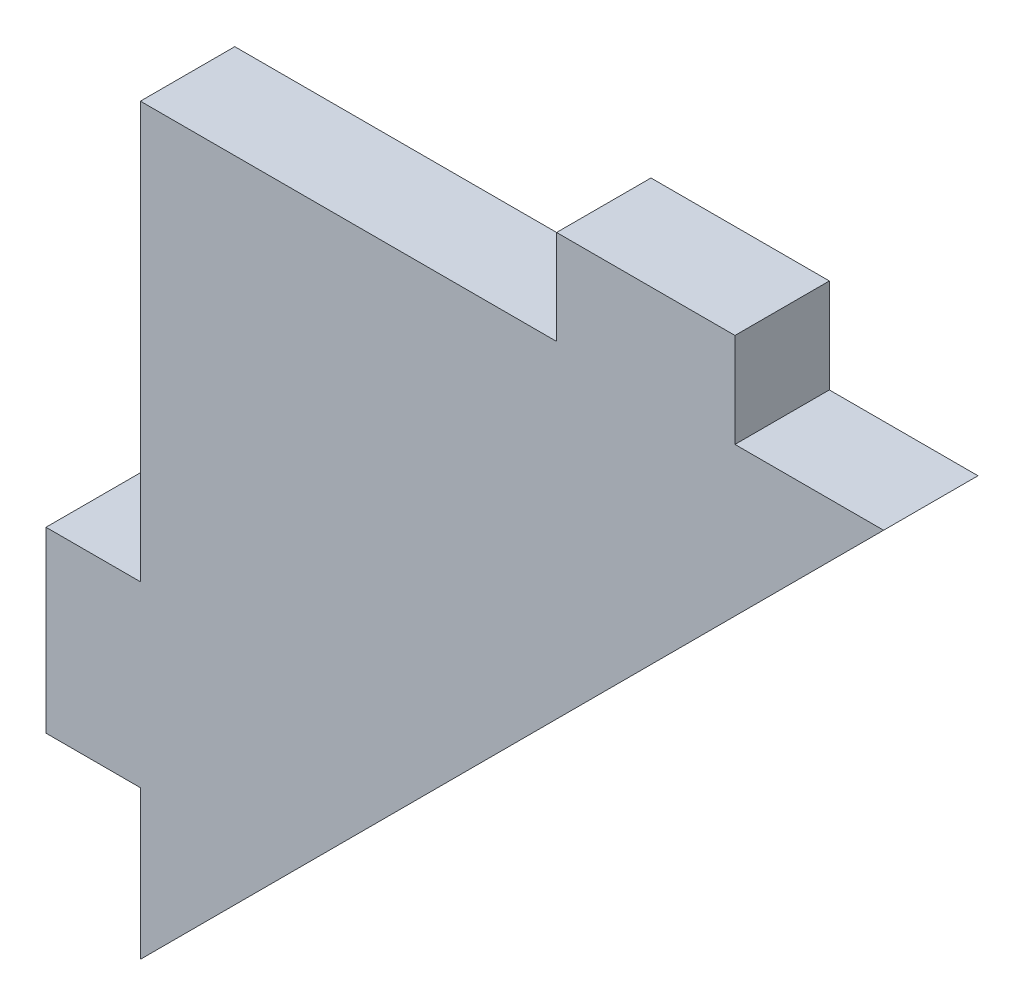
from build123d import *

# Parameters (mm, degrees)
BOSS_EXTRUDE1_DEPTH = 1.5875


with BuildPart() as part:
    # Sketch2 → Boss-Extrude1 (new body, symmetric)
    with BuildSketch(Plane.XY):
        Polygon((0, 25), (0, 11), (-3.175, 11), (-3.175, 5), (0, 5), (0, 0), (25, 25), (20, 25), (20, 28.175), (14, 28.175), (14, 25), align=None)
    extrude(amount=BOSS_EXTRUDE1_DEPTH, both=True)


solid = part.part
